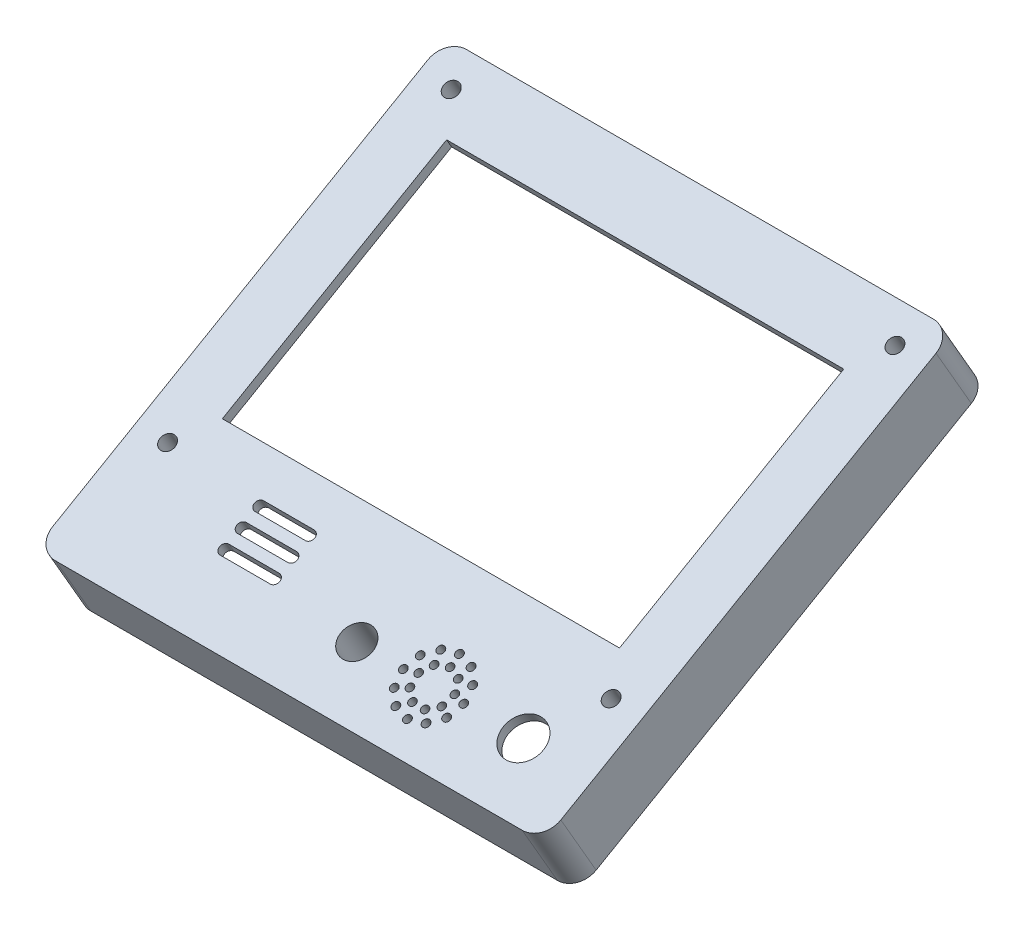
from build123d import *

# Parameters (mm, degrees)
SKETCH3_W           = 100751.030623597
SKETCH3_H           = 94095.793284763
BOSS_EXTRUDE1_DEPTH = 14000
SHELL1_T            = -2000
SKETCH5_R           = 1501.792292058
SKETCH5_R_2         = 1493.687333369
SKETCH5_R_3         = 1490.724890678
SKETCH5_R_4         = 3982.172835147
SKETCH5_R_5         = 3170.60939126
SKETCH5_R_6         = 1490.363986071
SKETCH5_R_7         = 737.911888342
SKETCH5_R_8         = 740.868588869
SKETCH5_R_9         = 724.590945863
SKETCH5_R_10        = 724.125890616
SKETCH5_R_11        = 734.985503275
SKETCH5_W           = 78736.278232061
SKETCH5_H           = 51336.053407304
CUT_EXTRUDE1_DEPTH  = 54745.673686927
SKETCH7_R           = 3521.682434345
SKETCH7_R_2         = 3500
SKETCH7_R_3         = 4000
BOSS_EXTRUDE2_DEPTH = 6300
SKETCH8_R           = 3170.60939126
SKETCH8_R_2         = 1490.363986071
SKETCH8_R_3         = 1501.792292058
SKETCH8_R_4         = 1493.687333369
SKETCH8_R_5         = 1490.724890678
CUT_EXTRUDE2_DEPTH  = 52745.673686927
FILLET1_R           = 4100


with BuildPart() as part:
    # Sketch3 → Boss-Extrude1 (new body)
    with BuildSketch(Plane(origin=(0, 38745.976565316, 22370), x_dir=(1, 0, 0), z_dir=(0, 0.866025404, 0.5))):
        with Locations((0.672101581, -53368.424582)):
            Rectangle(SKETCH3_W, SKETCH3_H)
    extrude(amount=BOSS_EXTRUDE1_DEPTH)

    # Shell1
    shell1_openings = [part.faces().sort_by_distance(p)[0] for p in [
        (0.672101581, 12061.764274316, 68588.411447965),
    ]]
    offset(amount=SHELL1_T, openings=shell1_openings, kind=Kind.INTERSECTION)

    # Sketch5 → Cut-Extrude1 (cut, through all)
    with BuildSketch(Plane(origin=(0, 50870.332218298, 29370), x_dir=(1, 0, 0), z_dir=(0, 0.866025404, 0.5))):
        with Locations((-43988.642988716, -12447.86118339)):
            Circle(SKETCH5_R)
        with Locations((43969.858921507, -12425.496648286)):
            Circle(SKETCH5_R_2)
        with Locations((43990.171869975, -77427.118367554)):
            Circle(SKETCH5_R_3)
        with Locations((36420.678996585, -88766.891638688)):
            Circle(SKETCH5_R_4)
        with Locations((3383.428748484, -88760.799065072)):
            Circle(SKETCH5_R_5)
        with Locations((-43960.990588159, -77415.562559785)):
            Circle(SKETCH5_R_6)
        with Locations((12622.70964354, -88782.736651262)):
            Circle(SKETCH5_R_7)
        with Locations((13435.125802779, -91791.685227628)):
            Circle(SKETCH5_R_8)
        with Locations((15520.940800859, -90608.093588528)):
            Circle(SKETCH5_R_9)
        with Locations((15113.59271346, -88150.559972676)):
            Circle(SKETCH5_R_10)
        with Locations((16340.174739396, -86021.618091901)):
            Circle(SKETCH5_R_11)
        with Locations((18752.643650656, -85141.082169193)):
            Circle(SKETCH5_R_10)
        with Locations((21107.567803853, -86017.311065275)):
            Circle(SKETCH5_R_10)
        with Locations((22348.315287725, -88202.257409446)):
            Circle(SKETCH5_R_10)
        with Locations((21894.326565197, -90673.560524293)):
            Circle(SKETCH5_R_10)
        with Locations((19958.028005061, -92274.870216907)):
            Circle(SKETCH5_R_10)
        with Locations((17445.435223167, -92256.915885536)):
            Circle(SKETCH5_R_10)
        with Locations((13411.848268246, -85818.035470049)):
            Circle(SKETCH5_R_8)
        with Locations((15589.835663855, -83623.007736487)):
            Circle(SKETCH5_R_8)
        with Locations((18573.541944355, -82811.051655016)):
            Circle(SKETCH5_R_8)
        with Locations((21563.485421435, -83599.730201955)):
            Circle(SKETCH5_R_8)
        with Locations((23758.513154996, -85777.717597564)):
            Circle(SKETCH5_R_8)
        with Locations((24570.469236467, -88761.423878064)):
            Circle(SKETCH5_R_8)
        with Locations((23781.790689528, -91751.367355144)):
            Circle(SKETCH5_R_8)
        with Locations((21603.803293919, -93946.395088705)):
            Circle(SKETCH5_R_8)
        with Locations((18620.097013419, -94758.351170176)):
            Circle(SKETCH5_R_8)
        with Locations((15630.15353634, -93969.672623237)):
            Circle(SKETCH5_R_8)
        with BuildLine():
            Line((-24605.495027879, -77761.15742212), (-14621.25981654, -77761.15742212))
            ThreePointArc((-14621.25981654, -77761.15742212), (-13633.25454866, -78749.16269), (-14621.25981654, -79737.16795788))
            Line((-14621.25981654, -79737.16795788), (-24605.495027879, -79737.167957879))
            ThreePointArc((-24605.495027879, -79737.167957879), (-25593.500295759, -78749.16269), (-24605.495027879, -77761.15742212))
        make_face()
        with Locations((238.728370746, -44780.829769233)):
            Rectangle(SKETCH5_W, SKETCH5_H)
        with BuildLine():
            Line((-24597.360469483, -81751.779593879), (-14620.865597251, -81751.779593879))
            ThreePointArc((-14620.865597251, -81751.779593879), (-13613.569009088, -82759.076182042), (-14620.865597251, -83766.372770205))
            Line((-14620.865597251, -83766.372770205), (-24597.360469483, -83766.372770205))
            ThreePointArc((-24597.360469483, -83766.372770205), (-25604.657057646, -82759.076182042), (-24597.360469483, -81751.779593879))
        make_face()
        with BuildLine():
            Line((-24586.884137164, -85741.418474927), (-14643.554974413, -85741.418474927))
            ThreePointArc((-14643.554974413, -85741.418474927), (-13638.231381461, -86746.74206788), (-14643.554974413, -87752.065660833))
            Line((-14643.554974413, -87752.065660833), (-24586.884137164, -87752.065660833))
            ThreePointArc((-24586.884137164, -87752.065660833), (-25592.207730117, -86746.74206788), (-24586.884137164, -85741.418474927))
        make_face()
    extrude(amount=-CUT_EXTRUDE1_DEPTH, mode=Mode.SUBTRACT)

    # Sketch7 → Boss-Extrude2 (add)
    with BuildSketch(Plane(origin=(0, 49138.281410729, 28370), x_dir=(1, 0, 0), z_dir=(0, -0.866025404, -0.5))):
        with Locations((43969.858921507, 12425.496648286)):
            Circle(SKETCH7_R)
        with Locations((-43988.642988716, 12447.86118339)):
            Circle(SKETCH7_R)
        with Locations((-43960.990588159, 77415.562559785)):
            Circle(SKETCH7_R_2)
        with Locations((43990.171869975, 77427.118367554)):
            Circle(SKETCH7_R)
        with Locations((3383.428748484, 88760.799065072)):
            Circle(SKETCH7_R_3)
    extrude(amount=BOSS_EXTRUDE2_DEPTH)

    # Sketch8 → Cut-Extrude2 (cut, through all)
    with BuildSketch(Plane(origin=(0, 49138.281410729, 28370), x_dir=(1, 0, 0), z_dir=(0, 0.866025404, 0.5))):
        with Locations((3383.428748484, -88760.799065072)):
            Circle(SKETCH8_R)
        with Locations((-43960.990588159, -77415.562559785)):
            Circle(SKETCH8_R_2)
        with Locations((-43988.642988716, -12447.86118339)):
            Circle(SKETCH8_R_3)
        with Locations((43969.858921507, -12425.496648286)):
            Circle(SKETCH8_R_4)
        with Locations((43990.171869975, -77427.118367554)):
            Circle(SKETCH8_R_5)
    extrude(amount=-CUT_EXTRUDE2_DEPTH, mode=Mode.SUBTRACT)

    # Fillet1
    fillet1_edges = [part.edges().sort_by_distance(p)[0] for p in [
        (-50374.843210217, 41647.890421998, 31343.737761038),
        (50376.18741338, 41647.890421998, 31343.737761038),
        (50376.18741338, -5400.006220383, 112833.085134892),
        (-50374.843210217, -5400.006220383, 112833.085134892),
    ]]
    fillet(fillet1_edges, radius=FILLET1_R)


solid = part.part
